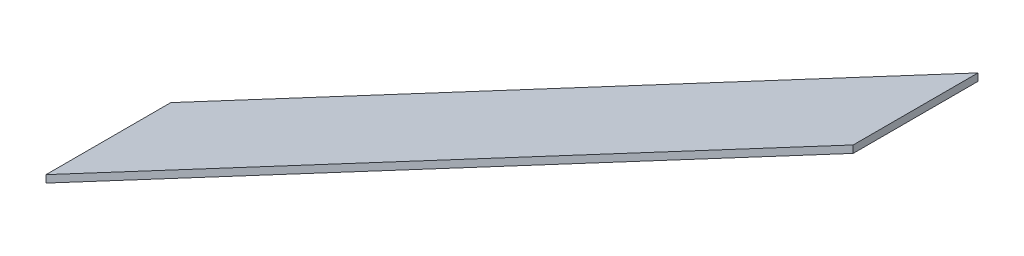
from build123d import *

# Parameters (mm, degrees)
EXTRUDE1_DEPTH = 850


with BuildPart() as part:
    # Sketch1 → Extrude1 (new body)
    with BuildSketch(Plane.XY):
        Polygon((-1000, -50), (-6499.448032305, -2975), (-6499.448032305, -2925), (-1000, 0), align=None)
    extrude(amount=-EXTRUDE1_DEPTH)


solid = part.part
